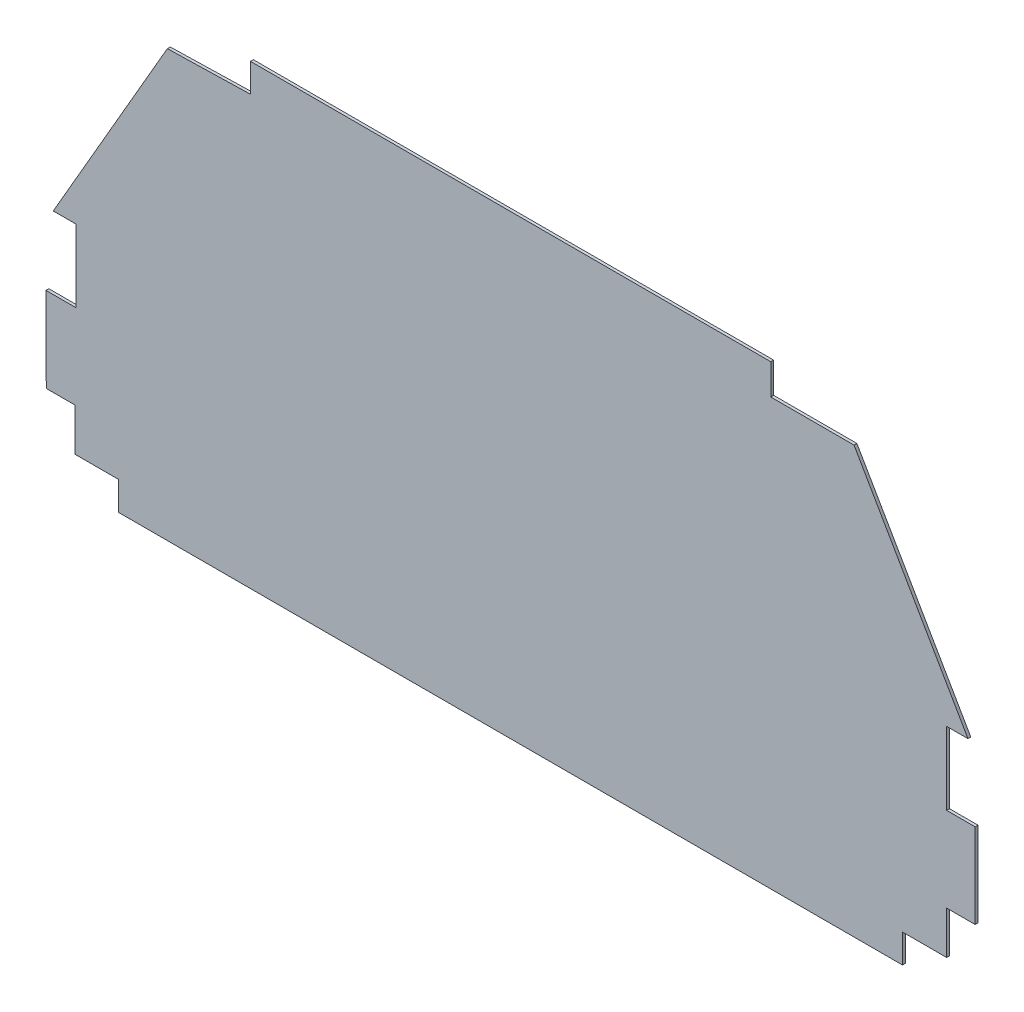
from build123d import *

# Parameters (mm, degrees)
BOSS_EXTRUDE1_DEPTH = 2


with BuildPart() as part:
    # Sketch1 → Boss-Extrude1 (new body)
    with BuildSketch(Plane.XY):
        Polygon((620.501751813, 140.30206511), (635.465126683, 140.30206511), (555.627271847, 278.585286054), (497.289305676, 278.585286054), (497.289305676, 300.001319811), (132.637060911, 300.001319811), (132.637060911, 280.002634605), (74.373165173, 278.585286054), (-5.60837801, 140.053189594), (10.267756977, 140.053189594), (10.267756977, 89.32006936), (-10.68927269, 89.32006936), (-10.5, 29.880209793), (9.498685206, 29.880209793), (9.498685206, -0.000432002), (40.283803364, -0.000432002), (40.283803364, -20.028400055), (589.589718053, -20.028400055), (589.589718053, -0.000432002), (620.501751813, -0.000432002), (620.501751813, 30.007474002), (640.500437019, 30.007474002), (640.500437019, 89.32006936), (620.501751813, 89.32006936), align=None)
    extrude(amount=BOSS_EXTRUDE1_DEPTH)


solid = part.part
